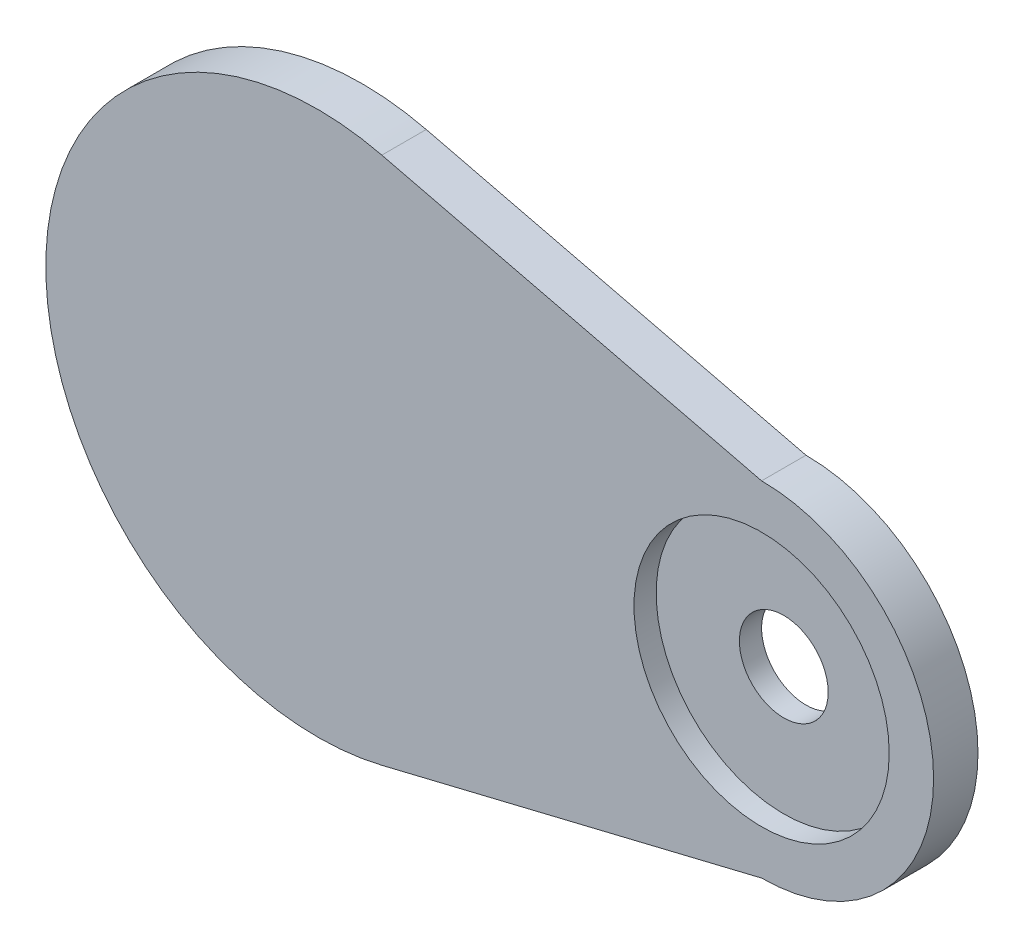
from build123d import *

# Parameters (mm, degrees)
EXTRUDE_1_DEPTH     = 4
SKETCH_2_R          = 11.5
CUT_EXTRUDE_1_DEPTH = 2
SKETCH_3_R          = 4
CUT_EXTRUDE_2_DEPTH = 2


with BuildPart() as part:
    # 草图1 → 凸台-拉伸1 (new body)
    with BuildSketch(Plane.XY):
        with BuildLine():
            Line((13.490639399, 16.366658186), (-20.728829372, 24.674964692))
            ThreePointArc((-20.728829372, 24.674964692), (-51.009360601, 0.866658186), (-20.728829372, -22.941648321))
            Line((-20.728829372, -22.941648321), (13.490639399, -14.633341814))
            ThreePointArc((13.490639399, -14.633341814), (28.990639399, 0.866658186), (13.490639399, 16.366658186))
        make_face()
    extrude(amount=EXTRUDE_1_DEPTH)

    # 草图2 → 切除-拉伸1 (cut)
    with BuildSketch(Plane.XY.offset(4)):
        with Locations((13.490639399, 0.866658186)):
            Circle(SKETCH_2_R)
    extrude(amount=-CUT_EXTRUDE_1_DEPTH, mode=Mode.SUBTRACT)

    # 草图3 → 切除-拉伸2 (cut)
    with BuildSketch(Plane.XY.offset(2)):
        with Locations((13.490639399, 0.866658186)):
            Circle(SKETCH_3_R)
    extrude(amount=-CUT_EXTRUDE_2_DEPTH, mode=Mode.SUBTRACT)


solid = part.part
